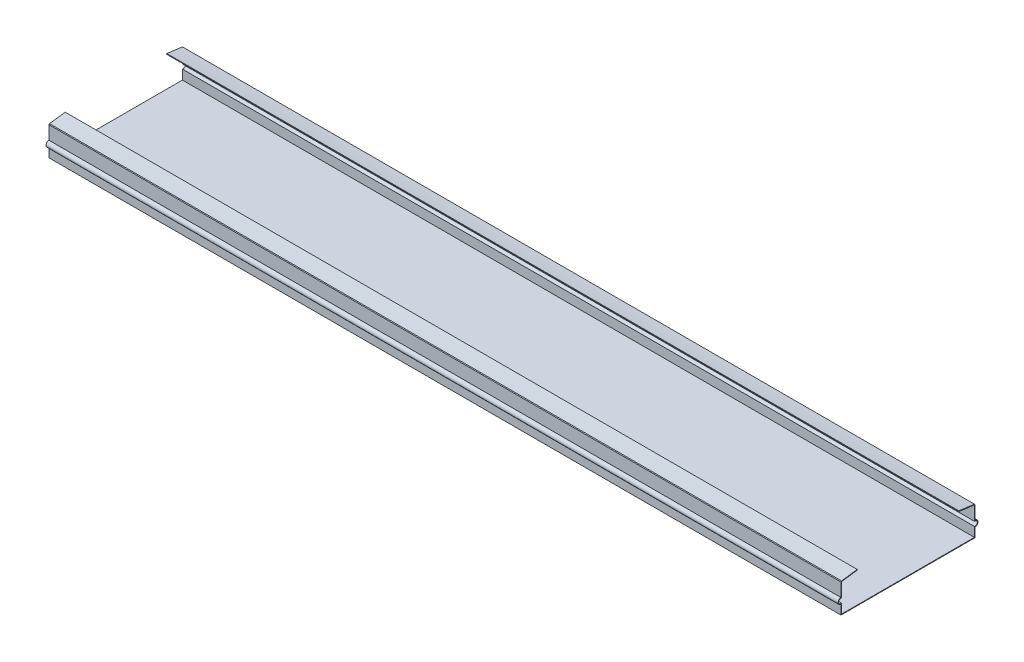
from build123d import *

# Parameters (mm, degrees)
SKETCH1_W           = 254
SKETCH1_H           = 43
BOSS_EXTRUDE1_DEPTH = 0.2
BOSS_EXTRUDE2_DEPTH = 254


with BuildPart() as part:
    # Sketch1 → Boss-Extrude1 (new body)
    with BuildSketch(Plane(origin=(0, 0, 0), x_dir=(1, 0, 0), z_dir=(0, 1, 0))):
        with Locations((-6.018162295, 0)):
            Rectangle(SKETCH1_W, SKETCH1_H)
    extrude(amount=BOSS_EXTRUDE1_DEPTH)

    # Sketch4 → Boss-Extrude2 (add)
    with BuildSketch(Plane(origin=(-133.018162295, 0, 0), x_dir=(0, 0, -1), z_dir=(1, 0, 0))):
        with BuildLine():
            Line((21.5, 0.2), (21.5, 3.005611905))
            ThreePointArc((21.5, 3.005611905), (22.439298034, 3.944909939), (21.5, 4.884207973))
            Line((21.5, 4.884207973), (21.5, 9.2))
            Line((21.5, 9.2), (21.317120226, 9.402181424))
            add(Edge.make_bspline(
                [(21.317120226, 9.402181424), (19.631812119, 9.571563167), (17.951135022, 9.796064061), (16.280476178, 10.075084883)],
                knots=[0, 0, 0, 0, 1, 1, 1, 1], degree=3))
            Line((16.280476178, 10.075084883), (16.247002876, 9.874660887))
            add(Edge.make_bspline(
                [(21.2968, 9.2), (18.759973351, 9.454963539), (16.247002876, 9.874660887)],
                knots=[0, 0, 0, 1, 1, 1], degree=2))
            Line((21.2968, 9.2), (21.2968, 4.652405576))
            ThreePointArc((21.2968, 4.652405576), (22.236098034, 3.944909939), (21.2968, 3.237414303))
            Line((21.2968, 3.237414303), (21.2968, 0.2))
            Line((21.2968, 0.2), (21.5, 0.2))
        make_face()
    boss_extrude2 = extrude(amount=BOSS_EXTRUDE2_DEPTH)

    # Mirror1: Boss-Extrude2 across plane
    add(boss_extrude2.mirror(Plane.XY))


solid = part.part
